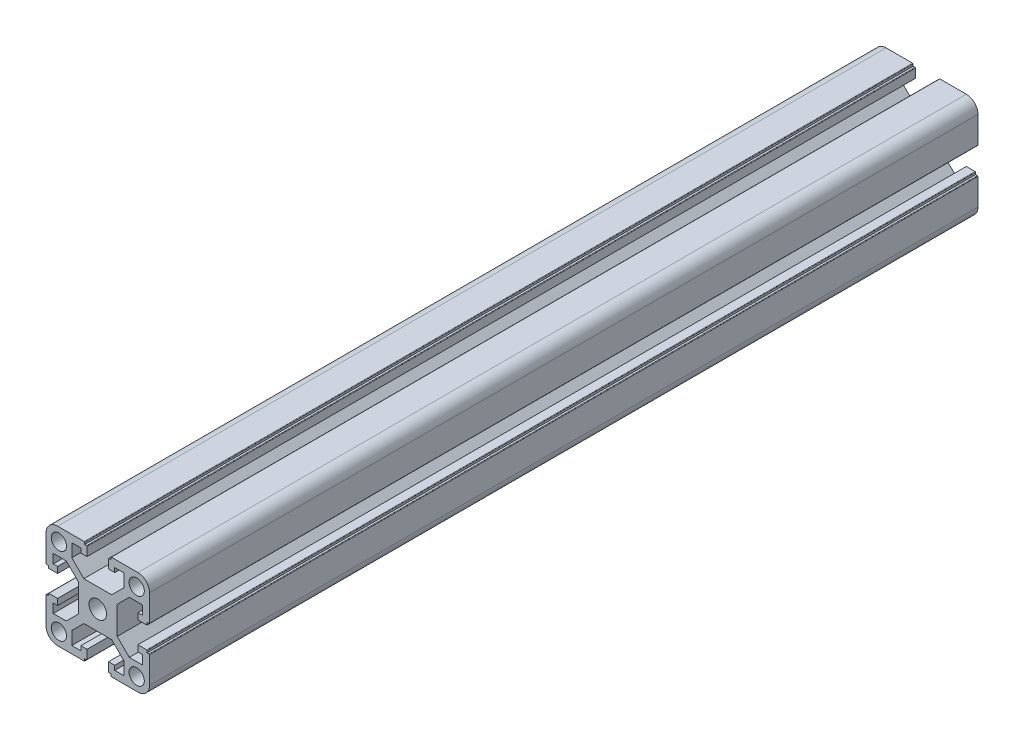
from build123d import *

# Parameters (mm, degrees)
SKETCH_1_R      = 2.95
SKETCH_1_R_2    = 3.4
EXTRUDE_1_DEPTH = 160


with BuildPart() as part:
    # 草图1 → 凸台-拉伸1 (new body, symmetric)
    with BuildSketch(Plane.XY.offset(50)):
        with BuildLine():
            Line((-1518.245004392, 3588.004280474), (-1518.245004392, 3582.975600817))
            Line((-1518.245004392, 3582.975600817), (-1522.916324736, 3578.304280474))
            Line((-1522.916324736, 3578.304280474), (-1533.673684048, 3578.304280474))
            Line((-1533.673684048, 3578.304280474), (-1538.345004392, 3582.975600817))
            Line((-1538.345004392, 3582.975600817), (-1538.345004392, 3588.004280474))
            Line((-1538.345004392, 3588.004280474), (-1534.845004392, 3588.004280474))
            Line((-1534.845004392, 3588.004280474), (-1534.845004392, 3586.304280474))
            Line((-1534.845004392, 3586.304280474), (-1532.445004392, 3586.304280474))
            Line((-1532.445004392, 3586.304280474), (-1532.445004392, 3589.704280474))
            ThreePointArc((-1532.445004392, 3589.704280474), (-1532.503583036, 3589.84570183), (-1532.645004392, 3589.904280474))
            Line((-1532.645004392, 3589.904280474), (-1533.345004392, 3589.904280474))
            Line((-1533.345004392, 3589.904280474), (-1533.345004392, 3590.604280474))
            ThreePointArc((-1533.345004392, 3590.604280474), (-1533.403583036, 3590.74570183), (-1533.545004392, 3590.804280474))
            Line((-1533.545004392, 3590.804280474), (-1543.795004392, 3590.804280474))
            ThreePointArc((-1543.795004392, 3590.804280474), (-1546.976984907, 3589.486260989), (-1548.295004392, 3586.304280474))
            Line((-1548.295004392, 3586.304280474), (-1548.295004392, 3576.054280474))
            ThreePointArc((-1548.295004392, 3576.054280474), (-1548.236425748, 3575.912859117), (-1548.095004392, 3575.854280474))
            Line((-1548.095004392, 3575.854280474), (-1547.395004392, 3575.854280474))
            Line((-1547.395004392, 3575.854280474), (-1547.395004392, 3575.154280474))
            ThreePointArc((-1547.395004392, 3575.154280474), (-1547.336425748, 3575.012859117), (-1547.195004392, 3574.954280474))
            Line((-1547.195004392, 3574.954280474), (-1543.795004392, 3574.954280474))
            Line((-1543.795004392, 3574.954280474), (-1543.795004392, 3577.354280474))
            Line((-1543.795004392, 3577.354280474), (-1545.495004392, 3577.354280474))
            Line((-1545.495004392, 3577.354280474), (-1545.495004392, 3580.854280474))
            Line((-1545.495004392, 3580.854280474), (-1540.466324736, 3580.854280474))
            Line((-1540.466324736, 3580.854280474), (-1535.795004392, 3576.18296013))
            Line((-1535.795004392, 3576.18296013), (-1535.795004392, 3565.425600817))
            Line((-1535.795004392, 3565.425600817), (-1540.466324736, 3560.754280474))
            Line((-1540.466324736, 3560.754280474), (-1545.495004392, 3560.754280474))
            Line((-1545.495004392, 3560.754280474), (-1545.495004392, 3564.254280474))
            Line((-1545.495004392, 3564.254280474), (-1543.795004392, 3564.254280474))
            Line((-1543.795004392, 3564.254280474), (-1543.795004392, 3566.654280474))
            Line((-1543.795004392, 3566.654280474), (-1547.195004392, 3566.654280474))
            ThreePointArc((-1547.195004392, 3566.654280474), (-1547.336425748, 3566.59570183), (-1547.395004392, 3566.454280474))
            Line((-1547.395004392, 3566.454280474), (-1547.395004392, 3565.754280474))
            Line((-1547.395004392, 3565.754280474), (-1548.095004392, 3565.754280474))
            ThreePointArc((-1548.095004392, 3565.754280474), (-1548.236425748, 3565.69570183), (-1548.295004392, 3565.554280474))
            Line((-1548.295004392, 3565.554280474), (-1548.295004392, 3555.304280474))
            ThreePointArc((-1548.295004392, 3555.304280474), (-1546.976984907, 3552.122299958), (-1543.795004392, 3550.804280474))
            Line((-1543.795004392, 3550.804280474), (-1533.545004392, 3550.804280474))
            ThreePointArc((-1533.545004392, 3550.804280474), (-1533.403583036, 3550.862859117), (-1533.345004392, 3551.004280474))
            Line((-1533.345004392, 3551.004280474), (-1533.345004392, 3551.704280474))
            Line((-1533.345004392, 3551.704280474), (-1532.645004392, 3551.704280474))
            ThreePointArc((-1532.645004392, 3551.704280474), (-1532.503583036, 3551.762859117), (-1532.445004392, 3551.904280474))
            Line((-1532.445004392, 3551.904280474), (-1532.445004392, 3555.304280474))
            Line((-1532.445004392, 3555.304280474), (-1534.845004392, 3555.304280474))
            Line((-1534.845004392, 3555.304280474), (-1534.845004392, 3553.604280474))
            Line((-1534.845004392, 3553.604280474), (-1538.345004392, 3553.604280474))
            Line((-1538.345004392, 3553.604280474), (-1538.345004392, 3558.63296013))
            Line((-1538.345004392, 3558.63296013), (-1533.673684048, 3563.304280474))
            Line((-1533.673684048, 3563.304280474), (-1522.916324736, 3563.304280474))
            Line((-1522.916324736, 3563.304280474), (-1518.245004392, 3558.63296013))
            Line((-1518.245004392, 3558.63296013), (-1518.245004392, 3553.604280474))
            Line((-1518.245004392, 3553.604280474), (-1521.745004392, 3553.604280474))
            Line((-1521.745004392, 3553.604280474), (-1521.745004392, 3555.304280474))
            Line((-1521.745004392, 3555.304280474), (-1524.145004392, 3555.304280474))
            Line((-1524.145004392, 3555.304280474), (-1524.145004392, 3551.904280474))
            ThreePointArc((-1524.145004392, 3551.904280474), (-1524.086425748, 3551.762859117), (-1523.945004392, 3551.704280474))
            Line((-1523.945004392, 3551.704280474), (-1523.245004392, 3551.704280474))
            Line((-1523.245004392, 3551.704280474), (-1523.245004392, 3551.004280474))
            ThreePointArc((-1523.245004392, 3551.004280474), (-1523.186425748, 3550.862859117), (-1523.045004392, 3550.804280474))
            Line((-1523.045004392, 3550.804280474), (-1512.795004392, 3550.804280474))
            ThreePointArc((-1512.795004392, 3550.804280474), (-1509.613023877, 3552.122299958), (-1508.295004392, 3555.304280474))
            Line((-1508.295004392, 3555.304280474), (-1508.295004392, 3565.554280474))
            ThreePointArc((-1508.295004392, 3565.554280474), (-1508.353583036, 3565.69570183), (-1508.495004392, 3565.754280474))
            Line((-1508.495004392, 3565.754280474), (-1509.195004392, 3565.754280474))
            Line((-1509.195004392, 3565.754280474), (-1509.195004392, 3566.454280474))
            ThreePointArc((-1509.195004392, 3566.454280474), (-1509.253583036, 3566.59570183), (-1509.395004392, 3566.654280474))
            Line((-1509.395004392, 3566.654280474), (-1512.795004392, 3566.654280474))
            Line((-1512.795004392, 3566.654280474), (-1512.795004392, 3564.254280474))
            Line((-1512.795004392, 3564.254280474), (-1511.095004392, 3564.254280474))
            Line((-1511.095004392, 3564.254280474), (-1511.095004392, 3560.754280474))
            Line((-1511.095004392, 3560.754280474), (-1516.123684048, 3560.754280474))
            Line((-1516.123684048, 3560.754280474), (-1520.795004392, 3565.425600817))
            Line((-1520.795004392, 3565.425600817), (-1520.795004392, 3576.18296013))
            Line((-1520.795004392, 3576.18296013), (-1516.123684048, 3580.854280474))
            Line((-1516.123684048, 3580.854280474), (-1511.095004392, 3580.854280474))
            Line((-1511.095004392, 3580.854280474), (-1511.095004392, 3577.354280474))
            Line((-1511.095004392, 3577.354280474), (-1512.795004392, 3577.354280474))
            Line((-1512.795004392, 3577.354280474), (-1512.795004392, 3574.954280474))
            Line((-1512.795004392, 3574.954280474), (-1509.395004392, 3574.954280474))
            ThreePointArc((-1509.395004392, 3574.954280474), (-1509.253583036, 3575.012859117), (-1509.195004392, 3575.154280474))
            Line((-1509.195004392, 3575.154280474), (-1509.195004392, 3575.854280474))
            Line((-1509.195004392, 3575.854280474), (-1508.495004392, 3575.854280474))
            ThreePointArc((-1508.495004392, 3575.854280474), (-1508.353583036, 3575.912859117), (-1508.295004392, 3576.054280474))
            Line((-1508.295004392, 3576.054280474), (-1508.295004392, 3586.304280474))
            ThreePointArc((-1508.295004392, 3586.304280474), (-1509.613023877, 3589.486260989), (-1512.795004392, 3590.804280474))
            Line((-1512.795004392, 3590.804280474), (-1523.045004392, 3590.804280474))
            ThreePointArc((-1523.045004392, 3590.804280474), (-1523.186425748, 3590.74570183), (-1523.245004392, 3590.604280474))
            Line((-1523.245004392, 3590.604280474), (-1523.245004392, 3589.904280474))
            Line((-1523.245004392, 3589.904280474), (-1523.945004392, 3589.904280474))
            ThreePointArc((-1523.945004392, 3589.904280474), (-1524.086425748, 3589.84570183), (-1524.145004392, 3589.704280474))
            Line((-1524.145004392, 3589.704280474), (-1524.145004392, 3586.304280474))
            Line((-1524.145004392, 3586.304280474), (-1521.745004392, 3586.304280474))
            Line((-1521.745004392, 3586.304280474), (-1521.745004392, 3588.004280474))
            Line((-1521.745004392, 3588.004280474), (-1518.245004392, 3588.004280474))
        make_face()
        with Locations((-1513.270004392, 3555.779280474)):
            Circle(SKETCH_1_R, mode=Mode.SUBTRACT)
        with Locations((-1528.295004392, 3570.804280474)):
            Circle(SKETCH_1_R_2, mode=Mode.SUBTRACT)
        with Locations((-1513.270004392, 3585.829280474)):
            Circle(SKETCH_1_R, mode=Mode.SUBTRACT)
        with Locations((-1543.320004392, 3585.829280474)):
            Circle(SKETCH_1_R, mode=Mode.SUBTRACT)
        with Locations((-1543.320004392, 3555.779280474)):
            Circle(SKETCH_1_R, mode=Mode.SUBTRACT)
    extrude(amount=EXTRUDE_1_DEPTH, both=True)


solid = part.part
